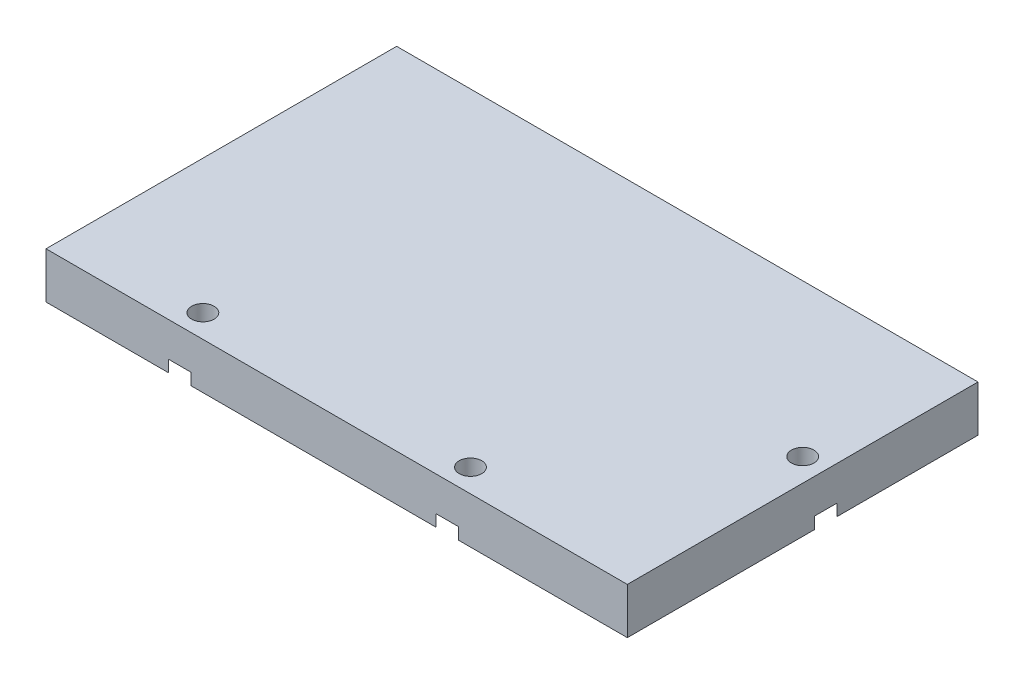
from build123d import *

# Parameters (mm, degrees)
SKETCH1_W                                           = 63
SKETCH1_H                                           = 38
BOSS_EXTRUDE1_DEPTH                                 = 5
CBORE_FOR_2_BINDING_HEAD_MACHINE_SCREW2_D           = 2.4384
CBORE_FOR_2_BINDING_HEAD_MACHINE_SCREW2_CBORE_D     = 5.55752
CBORE_FOR_2_BINDING_HEAD_MACHINE_SCREW2_CBORE_DEPTH = 1.27
CBORE_FOR_2_BINDING_HEAD_MACHINE_SCREW3_D           = 2.4384
CBORE_FOR_2_BINDING_HEAD_MACHINE_SCREW3_CBORE_D     = 5.55752
CBORE_FOR_2_BINDING_HEAD_MACHINE_SCREW3_CBORE_DEPTH = 1.27
F_2_56_TAPPED_HOLE1_D                               = 1.778
F_2_56_TAPPED_HOLE1_DEPTH                           = 9.46583491
F_2_56_TAPPED_HOLE1_TIP                             = 0.53416509


with BuildPart() as part:
    # Sketch1 → Boss-Extrude1 (new body)
    with BuildSketch(Plane(origin=(0, 0, 0), x_dir=(1, 0, 0), z_dir=(0, 1, 0))):
        Rectangle(SKETCH1_W, SKETCH1_H)
    extrude(amount=BOSS_EXTRUDE1_DEPTH)

    # CBORE for #2 Binding Head Machine Screw2 (through all)
    with Locations(Plane(origin=(0, 0, 0), x_dir=(-1, 0, 0), z_dir=(0, -1, 0))):
        with Locations((-29, 2.5)):
            CounterBoreHole(CBORE_FOR_2_BINDING_HEAD_MACHINE_SCREW2_D / 2, CBORE_FOR_2_BINDING_HEAD_MACHINE_SCREW2_CBORE_D / 2, CBORE_FOR_2_BINDING_HEAD_MACHINE_SCREW2_CBORE_DEPTH)

    # CBORE for #2 Binding Head Machine Screw3 (through all)
    with Locations(Plane(origin=(0, 0, 0), x_dir=(-1, 0, 0), z_dir=(0, -1, 0))):
        with Locations((-12, -16.5), (17, -16.5)):
            CounterBoreHole(CBORE_FOR_2_BINDING_HEAD_MACHINE_SCREW3_D / 2, CBORE_FOR_2_BINDING_HEAD_MACHINE_SCREW3_CBORE_D / 2, CBORE_FOR_2_BINDING_HEAD_MACHINE_SCREW3_CBORE_DEPTH)

    # #2-56 Tapped Hole1
    with Locations(Plane(origin=(0, 0, -19), x_dir=(-1, 0, 0), z_dir=(0, 0, -1))):
        with Locations((-11.79093, 2.5), (17.06969, 2.5)):
            Hole(F_2_56_TAPPED_HOLE1_D / 2, depth=F_2_56_TAPPED_HOLE1_DEPTH)
            with Locations((0, 0, -(F_2_56_TAPPED_HOLE1_DEPTH + F_2_56_TAPPED_HOLE1_TIP / 2))):  # 118° drill point
                Cone(0, F_2_56_TAPPED_HOLE1_D / 2, F_2_56_TAPPED_HOLE1_TIP, mode=Mode.SUBTRACT)


solid = part.part
